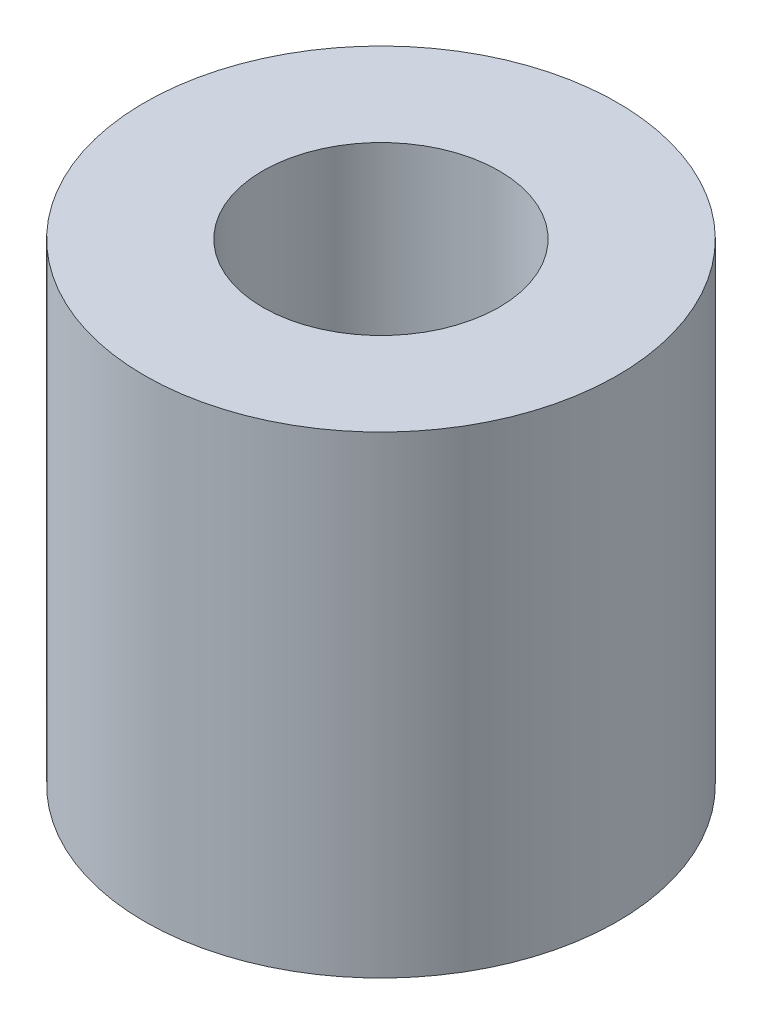
from build123d import *

# Parameters (mm, degrees)
ESQUISSE1_R      = 10
ESQUISSE1_R_2    = 5
EXTRUSION1_DEPTH = 20


with BuildPart() as part:
    # Esquisse1 → Extrusion1 (new body)
    with BuildSketch(Plane(origin=(0, 0, 0), x_dir=(1, 0, 0), z_dir=(0, 1, 0))):
        Circle(ESQUISSE1_R)
        Circle(ESQUISSE1_R_2, mode=Mode.SUBTRACT)
    extrude(amount=EXTRUSION1_DEPTH)


solid = part.part
